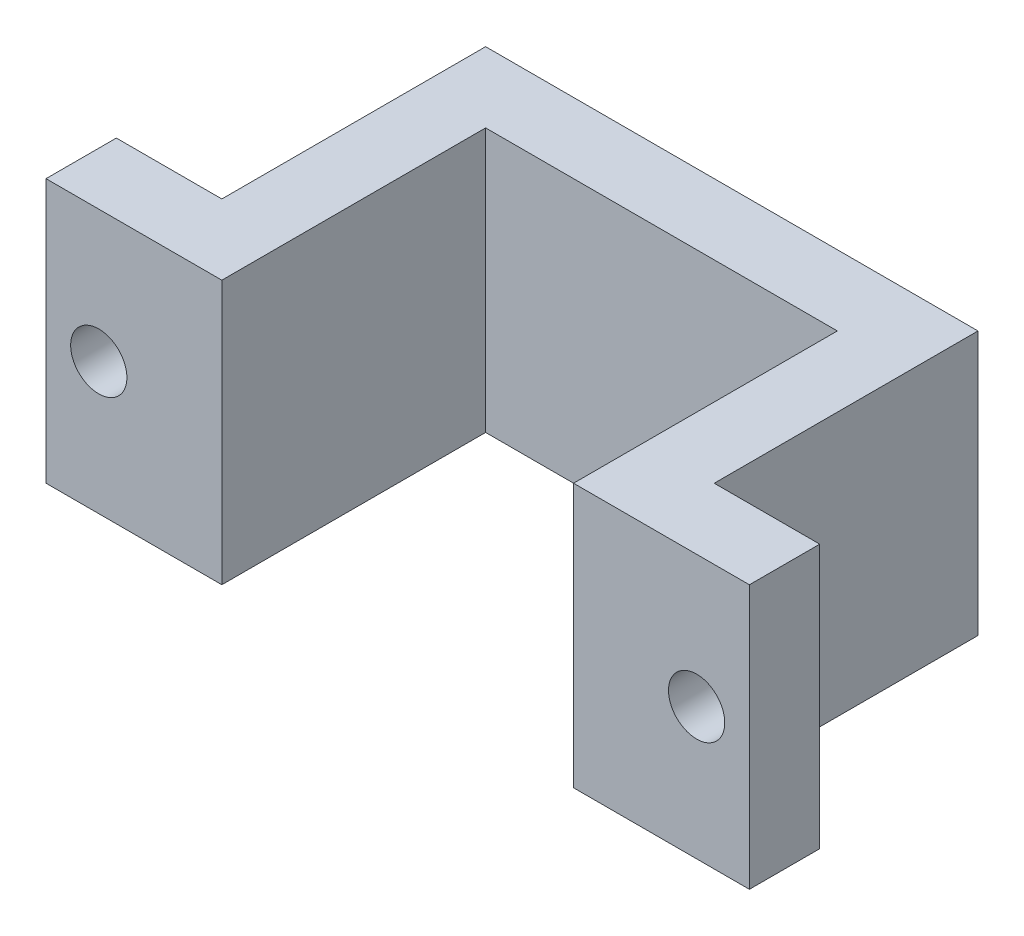
from build123d import *

# Parameters (mm, degrees)
BOSS_EXTRUDE1_DEPTH = 9.525
CUT_EXTRUDE1_REACH  = 4.54
SKETCH2_R           = 1.016


with BuildPart() as part:
    # Sketch1 → Boss-Extrude1 (new body)
    with BuildSketch(Plane(origin=(0, 0, 0), x_dir=(1, 0, 0), z_dir=(0, 1, 0))):
        Polygon((0, 0), (6.35, 0), (6.35, 9.525), (19.05, 9.525), (19.05, 0), (25.4, 0), (25.4, 2.54), (21.59, 2.54), (21.59, 12.065), (3.81, 12.065), (3.81, 2.54), (0, 2.54), align=None)
    extrude(amount=BOSS_EXTRUDE1_DEPTH)

    # Sketch2 → Cut-Extrude1 (cut, up to next)
    with BuildSketch(Plane(origin=(0, 0, -2.54), x_dir=(-1, 0, 0), z_dir=(0, 0, -1)), mode=Mode.PRIVATE) as cut_extrude1_sk1:
        with Locations((-1.905, 4.7625)):
            Circle(SKETCH2_R)
    cut_extrude1_tool1 = extrude(cut_extrude1_sk1.sketch, amount=-CUT_EXTRUDE1_REACH, mode=Mode.PRIVATE) & part.part
    add(cut_extrude1_tool1.solids().sort_by_distance((1.905, 4.7625, -2.54))[0], mode=Mode.SUBTRACT)
    # Sketch2 → Cut-Extrude1 (cut, up to next)
    with BuildSketch(Plane(origin=(0, 0, -2.54), x_dir=(-1, 0, 0), z_dir=(0, 0, -1)), mode=Mode.PRIVATE) as cut_extrude1_sk2:
        with Locations((-23.495, 4.7625)):
            Circle(SKETCH2_R)
    cut_extrude1_tool2 = extrude(cut_extrude1_sk2.sketch, amount=-CUT_EXTRUDE1_REACH, mode=Mode.PRIVATE) & part.part
    add(cut_extrude1_tool2.solids().sort_by_distance((23.495, 4.7625, -2.54))[0], mode=Mode.SUBTRACT)


solid = part.part
